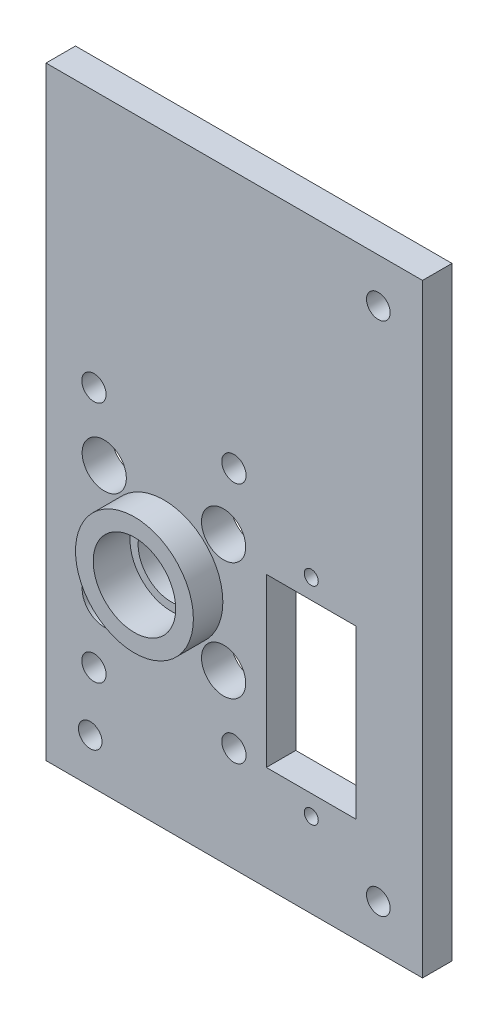
from build123d import *

# Parameters (mm, degrees)
SKETCH1_W               = 39.1
SKETCH1_H               = 33
SKETCH1_R               = 0.95
SKETCH1_R_2             = 4.5
SKETCH1_W_2             = 12.2
SKETCH1_H_2             = 22.7
BOSS_EXTRUDE1_DEPTH     = 4
BOSS_EXTRUDE2_START     = 4
SKETCH2_R               = 8
SKETCH2_R_2             = 4.403773093
BOSS_EXTRUDE2_DEPTH     = 4
CUT_EXTRUDE1_START      = 8
SKETCH3_R               = 5.6
CUT_EXTRUDE1_DEPTH      = 5
SKETCH5_W               = 39.1
SKETCH5_H               = 10
SKETCH5_W_2             = 6.003695208
SKETCH5_H_2             = 43
BOSS_EXTRUDE3_DEPTH     = 4
SKETCH4_R               = 1.65
CUT_EXTRUDE3_DEPTH      = 9
CUT_EXTRUDE3_DEPTH_BACK = 10
CUT_EXTRUDE4_START      = 4
SKETCH6_R               = 3
CUT_EXTRUDE4_DEPTH      = 10
SKETCH7_W               = 6
SKETCH7_H               = 43
BOSS_EXTRUDE4_DEPTH     = 4
SKETCH8_R               = 1.6
CUT_EXTRUDE6_DEPTH      = 4


with BuildPart() as part:
    # Sketch1 → Boss-Extrude1 (new body)
    with BuildSketch(Plane.XY):
        with Locations((-10.45, -5.15)):
            Rectangle(SKETCH1_W, SKETCH1_H)
        with Locations((0, 8.9)):
            Circle(SKETCH1_R, mode=Mode.SUBTRACT)
        with Locations((0, -19.2)):
            Circle(SKETCH1_R, mode=Mode.SUBTRACT)
        with Locations((-20, 0)):
            Circle(SKETCH1_R_2, mode=Mode.SUBTRACT)
        with Locations((0, -5.15)):
            Rectangle(SKETCH1_W_2, SKETCH1_H_2, mode=Mode.SUBTRACT)
    extrude(amount=BOSS_EXTRUDE1_DEPTH)

    # Sketch2 → Boss-Extrude2 (add)
    with BuildSketch(Plane.XY.offset(BOSS_EXTRUDE2_START)):
        with Locations((-20, 0)):
            Circle(SKETCH2_R)
        with Locations((-20, 0)):
            Circle(SKETCH2_R_2, mode=Mode.SUBTRACT)
    extrude(amount=BOSS_EXTRUDE2_DEPTH)

    # Sketch3 → Cut-Extrude1 (cut)
    with BuildSketch(Plane.XY.offset(CUT_EXTRUDE1_START)):
        with Locations((-20, 0)):
            Circle(SKETCH3_R)
    extrude(amount=-CUT_EXTRUDE1_DEPTH, mode=Mode.SUBTRACT)

    # Sketch5 → Boss-Extrude3 (add)
    with BuildSketch(Plane.XY):
        with Locations((-10.45, 16.35)):
            Rectangle(SKETCH5_W, SKETCH5_H)
        with Locations((-33.001847604, -0.15)):
            Rectangle(SKETCH5_W_2, SKETCH5_H_2)
    extrude(amount=BOSS_EXTRUDE3_DEPTH)

    # Sketch4 → Cut-Extrude3 (cut, two sides)
    with BuildSketch(Plane.XY) as cut_extrude3_sk:
        with Locations((-10.5, 16.454482672)):
            Circle(SKETCH4_R)
        with Locations((-29.5, 16.454482672)):
            Circle(SKETCH4_R)
        with Locations((-29.5, -16.454482672)):
            Circle(SKETCH4_R)
        with Locations((-10.5, -16.454482672)):
            Circle(SKETCH4_R)
    extrude(amount=CUT_EXTRUDE3_DEPTH, mode=Mode.SUBTRACT)
    extrude(cut_extrude3_sk.sketch, amount=-CUT_EXTRUDE3_DEPTH_BACK, mode=Mode.SUBTRACT)

    # Sketch6 → Cut-Extrude4 (cut)
    with BuildSketch(Plane.XY.offset(CUT_EXTRUDE4_START)):
        with Locations((-11.9, 8)):
            Circle(SKETCH6_R)
        with Locations((-28.1, 8)):
            Circle(SKETCH6_R)
        with Locations((-11.9, -8)):
            Circle(SKETCH6_R)
        with Locations((-28.1, -8)):
            Circle(SKETCH6_R)
    extrude(amount=-CUT_EXTRUDE4_DEPTH, mode=Mode.SUBTRACT)

    # Sketch7 → Boss-Extrude4 (add)
    with BuildSketch(Plane.XY):
        Polygon((9.1, -21.65), (-36.003695208, -21.65), (-36.003695208, -30.65), (15.1, -30.65), (15.1, -21.65), align=None)
        with Locations((12.1, -0.15)):
            Rectangle(SKETCH7_W, SKETCH7_H)
        Polygon((-36.003695208, 21.35), (9.1, 21.35), (15.1, 21.35), (15.1, 51.35), (-36.003695208, 51.35), align=None)
    extrude(amount=BOSS_EXTRUDE4_DEPTH)

    # Sketch8 → Cut-Extrude6 (cut)
    with BuildSketch(Plane.XY):
        with Locations((9.1, -24.65)):
            Circle(SKETCH8_R)
        with Locations((-30.003695208, -24.65)):
            Circle(SKETCH8_R)
        with Locations((9.1, 45.35)):
            Circle(SKETCH8_R)
    extrude(amount=CUT_EXTRUDE6_DEPTH, mode=Mode.SUBTRACT)


solid = part.part
